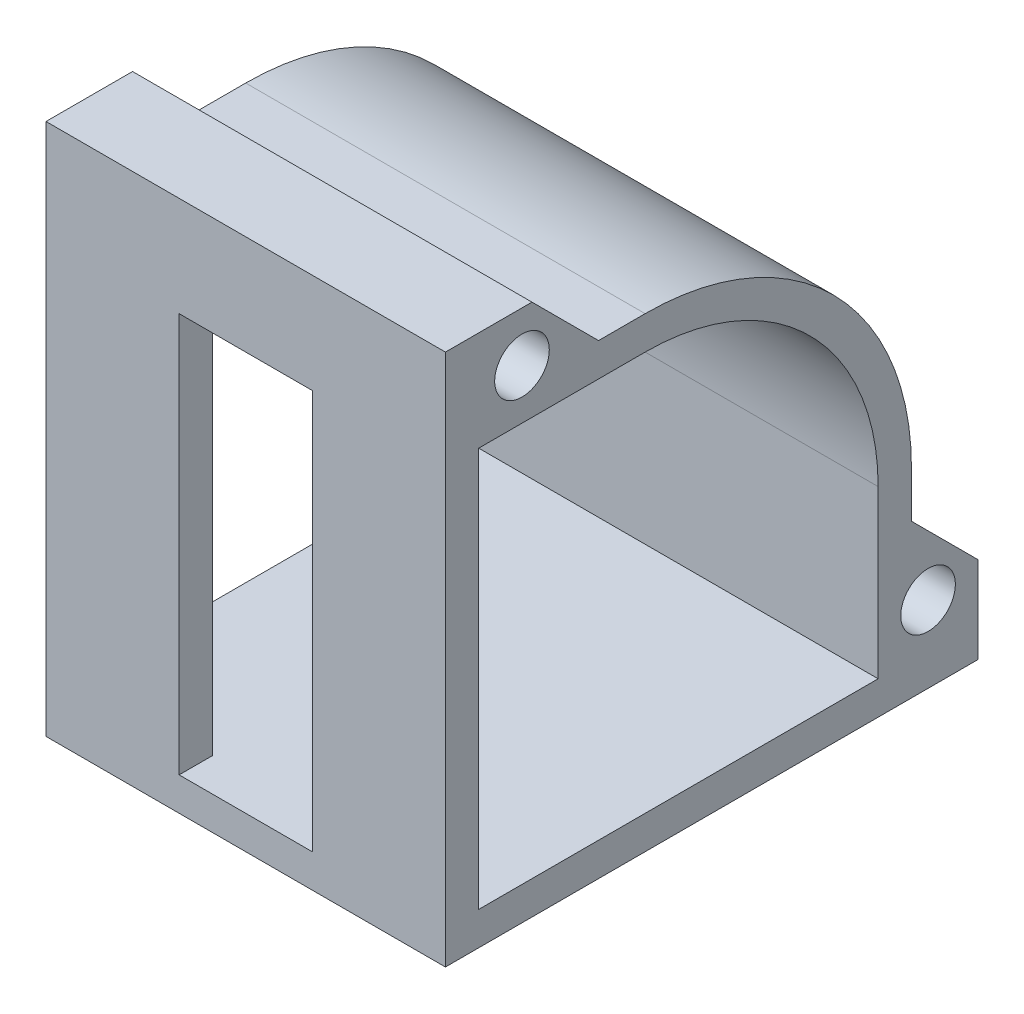
from build123d import *

# Parameters (mm, degrees)
BOSS_EXTRUDE1_DEPTH = 60
CUT_EXTRUDE1_DEPTH  = 7
CUT_EXTRUDE2_REACH  = 72
SKETCH5_W           = 20
SKETCH5_H           = 60
SKETCH6_W           = 23
SKETCH6_H           = 10
SKETCH6_W_2         = 10
SKETCH6_H_2         = 23
BOSS_EXTRUDE3_DEPTH = 60
SKETCH8_R           = 4.1
CUT_EXTRUDE3_DEPTH  = 61
CHAMFER2_SIZE       = 10
BOSS_EXTRUDE4_DEPTH = 7


with BuildPart() as part:
    # Sketch2 → Boss-Extrude1 (new body)
    with BuildSketch(Plane(origin=(0, 0, 0), x_dir=(0, 0, -1), z_dir=(1, 0, 0))):
        with BuildLine():
            Line((0, 40), (-30, 40))
            Line((-30, 40), (-30, -30))
            Line((-30, -30), (40, -30))
            Line((40, -30), (40, 0))
            ThreePointArc((40, 0), (28.284271247, 28.284271247), (0, 40))
        make_face()
        with BuildLine():
            Line((-25, 35), (-25, -25))
            Line((-25, -25), (35, -25))
            Line((35, -25), (35, 0))
            ThreePointArc((35, 0), (24.748737342, 24.748737342), (0, 35))
            Line((0, 35), (-25, 35))
        make_face(mode=Mode.SUBTRACT)
    extrude(amount=BOSS_EXTRUDE1_DEPTH)

    # Sketch4 → Cut-Extrude1 (cut)
    with BuildSketch(Plane(origin=(60, 0, 0), x_dir=(0, 0, -1), z_dir=(1, 0, 0))):
        with BuildLine():
            Line((0, 40), (-7, 40))
            Line((-7, 40), (-7, 35))
            Line((-7, 35), (0, 35))
            ThreePointArc((0, 35), (24.748737342, 24.748737342), (35, 0))
            Line((35, 0), (35, -7))
            Line((35, -7), (40, -7))
            Line((40, -7), (40, 0))
            ThreePointArc((40, 0), (28.284271247, 28.284271247), (0, 40))
        make_face()
    extrude(amount=-CUT_EXTRUDE1_DEPTH, mode=Mode.SUBTRACT)

    # Sketch5 → Cut-Extrude2 (cut, up to next)
    with BuildSketch(Plane.XY.offset(30), mode=Mode.PRIVATE) as cut_extrude2_sk1:
        with Locations((30, 5)):
            Rectangle(SKETCH5_W, SKETCH5_H)
    cut_extrude2_tool1 = extrude(cut_extrude2_sk1.sketch, amount=-CUT_EXTRUDE2_REACH, mode=Mode.PRIVATE) & part.part
    add(cut_extrude2_tool1.solids().sort_by_distance((30, 5, 30))[0], mode=Mode.SUBTRACT)

    # Sketch6 → Boss-Extrude3 (add)
    with BuildSketch(Plane(origin=(60, 0, 0), x_dir=(0, 0, -1), z_dir=(1, 0, 0))):
        with Locations((-18.5, 45)):
            Rectangle(SKETCH6_W, SKETCH6_H)
        with Locations((45, -18.5)):
            Rectangle(SKETCH6_W_2, SKETCH6_H_2)
    extrude(amount=-BOSS_EXTRUDE3_DEPTH)

    # Sketch8 → Cut-Extrude3 (cut, through all)
    with BuildSketch(Plane(origin=(60, 0, 0), x_dir=(0, 0, -1), z_dir=(1, 0, 0))):
        with Locations((-18.5, 42.5)):
            Circle(SKETCH8_R)
        with Locations((42.5, -18.5)):
            Circle(SKETCH8_R)
    extrude(amount=-CUT_EXTRUDE3_DEPTH, mode=Mode.SUBTRACT)

    # Chamfer2
    chamfer2_edges = [part.edges().sort_by_distance(p)[0] for p in [
        (30, -7, -50),
        (30, 50, 7),
    ]]
    chamfer(chamfer2_edges, length=CHAMFER2_SIZE)

    # Sketch9 → Boss-Extrude4 (add)
    with BuildSketch(Plane(origin=(53, 0, 0), x_dir=(0, 0, -1), z_dir=(1, 0, 0))):
        with BuildLine():
            Line((0, 40), (-7, 40))
            Line((-7, 40), (-7, 35))
            Line((-7, 35), (0, 35))
            ThreePointArc((0, 35), (24.748737342, 24.748737342), (35, 0))
            Line((35, 0), (35, -7))
            Line((35, -7), (40, -7))
            Line((40, -7), (40, 0))
            ThreePointArc((40, 0), (28.284271247, 28.284271247), (0, 40))
        make_face()
    extrude(amount=BOSS_EXTRUDE4_DEPTH)


solid = part.part
